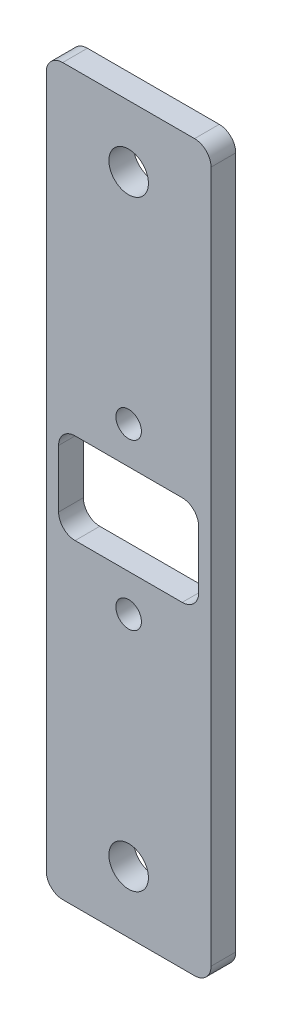
from build123d import *

# Parameters (mm, degrees)
SKETCH_1_W      = 88
SKETCH_1_H      = 20
SKETCH_1_R      = 2.4
SKETCH_1_R_2    = 1.55
SKETCH_1_W_2    = 11
SKETCH_1_H_2    = 17
EXTRUDE_1_DEPTH = 3
FILLET_1_R      = 2


with BuildPart() as part:
    # ｽｹｯﾁ1 → ﾎﾞｽ - 押し出し1 (new body)
    with BuildSketch(Plane(origin=(0, 0, 0), x_dir=(0, 1, 0), z_dir=(0, 0, 1))):
        with Locations((44, 10)):
            Rectangle(SKETCH_1_W, SKETCH_1_H)
        with Locations((7.5, 10)):
            Circle(SKETCH_1_R, mode=Mode.SUBTRACT)
        with Locations((80.5, 10)):
            Circle(SKETCH_1_R, mode=Mode.SUBTRACT)
        with Locations((54, 10)):
            Circle(SKETCH_1_R_2, mode=Mode.SUBTRACT)
        with Locations((34, 10)):
            Circle(SKETCH_1_R_2, mode=Mode.SUBTRACT)
        with Locations((44, 10)):
            Rectangle(SKETCH_1_W_2, SKETCH_1_H_2, mode=Mode.SUBTRACT)
    extrude(amount=EXTRUDE_1_DEPTH)

    # ﾌｨﾚｯﾄ1
    fillet_1_edges = [part.edges().sort_by_distance(p)[0] for p in [
        (-1.5, 49.5, 1.5),
        (-18.5, 49.5, 1.5),
        (-18.5, 38.5, 1.5),
        (-1.5, 38.5, 1.5),
        (-20, 0, 1.5),
        (-20, 88, 1.5),
        (0, 88, 1.5),
        (0, 0, 1.5),
    ]]
    fillet(fillet_1_edges, radius=FILLET_1_R)


solid = part.part
